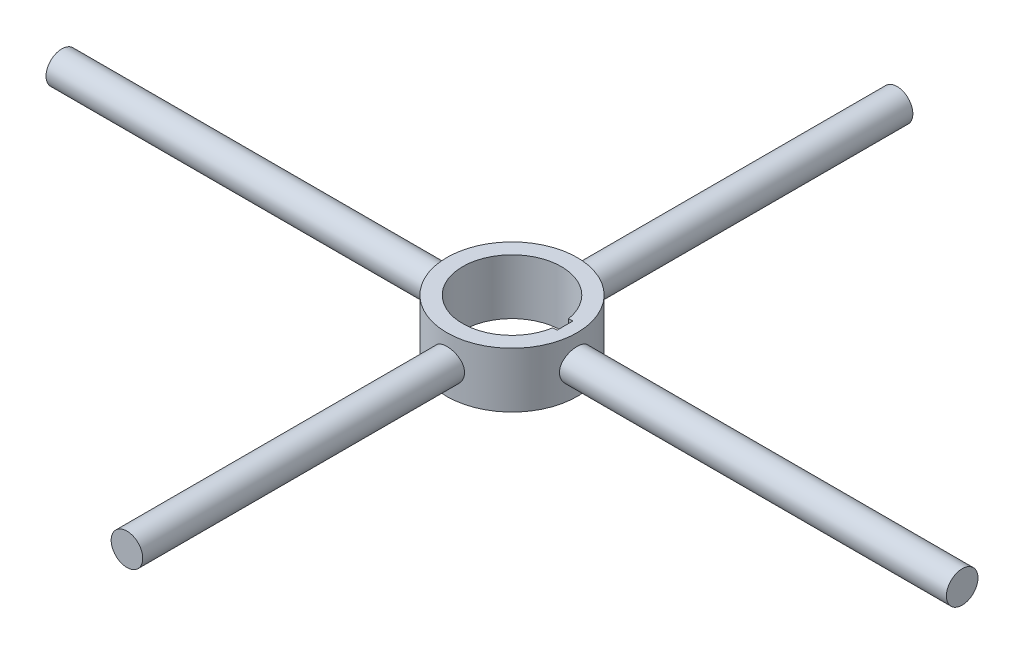
from build123d import *

# Parameters (mm, degrees)
SKETCH_1_R               = 82.5
EXTRUDE_1_DEPTH          = 70
EXTRUDE_START            = -407.460947
SKETCH_2_R               = 20
EXTRUDE_2_DEPTH          = 407.460947
EXTRUDE_START_2          = -489.960947
SKETCH_4_R               = 20
EXTRUDE_3_DEPTH          = 489.960947
PATTERN_CIRCULAR_2_COUNT = 2


with BuildPart() as part:
    # 스케치1 → 보스-돌출1 (new body)
    with BuildSketch(Plane(origin=(0, 0, 0), x_dir=(1, 0, 0), z_dir=(0, 1, 0))):
        with Locations(Location((0, 0, 0), (0, 0, 270))):  # turned: the seam where the file's is
            Circle(SKETCH_1_R)
        with BuildLine():
            Line((61.694813396, -10), (67, -10))
            Line((67, -10), (67, 10))
            Line((67, 10), (61.694813396, 10))
            ThreePointArc((61.694813396, 10), (-62.5, 0), (61.694813396, -10))
        make_face(mode=Mode.SUBTRACT)
    extrude(amount=EXTRUDE_1_DEPTH)

    # 스케치2 → 보스-돌출2 (add)
    with BuildSketch(Plane.XY.offset(487.5).offset(EXTRUDE_START)):
        with Locations((0, 35)):
            Circle(SKETCH_2_R)
    extrude_2 = extrude(amount=EXTRUDE_2_DEPTH)

    # 스케치4 → 보스-돌출3 (add)
    with BuildSketch(Plane(origin=(570, 0, 0), x_dir=(0, 0, -1), z_dir=(1, 0, 0)).offset(EXTRUDE_START_2)):
        with Locations((0, 35)):
            Circle(SKETCH_4_R)
    extrude_3 = extrude(amount=EXTRUDE_3_DEPTH)

    # 원형 패턴2: 보스-돌출2, 보스-돌출3 ×2 about axis
    pattern_circular_2_axis = Axis((0, 0, 0), (0, 1, 0))
    add([extrude_2.rotate(pattern_circular_2_axis, i * 360 / PATTERN_CIRCULAR_2_COUNT) for i in range(1, PATTERN_CIRCULAR_2_COUNT)])
    add([extrude_3.rotate(pattern_circular_2_axis, i * 360 / PATTERN_CIRCULAR_2_COUNT) for i in range(1, PATTERN_CIRCULAR_2_COUNT)])


solid = part.part
